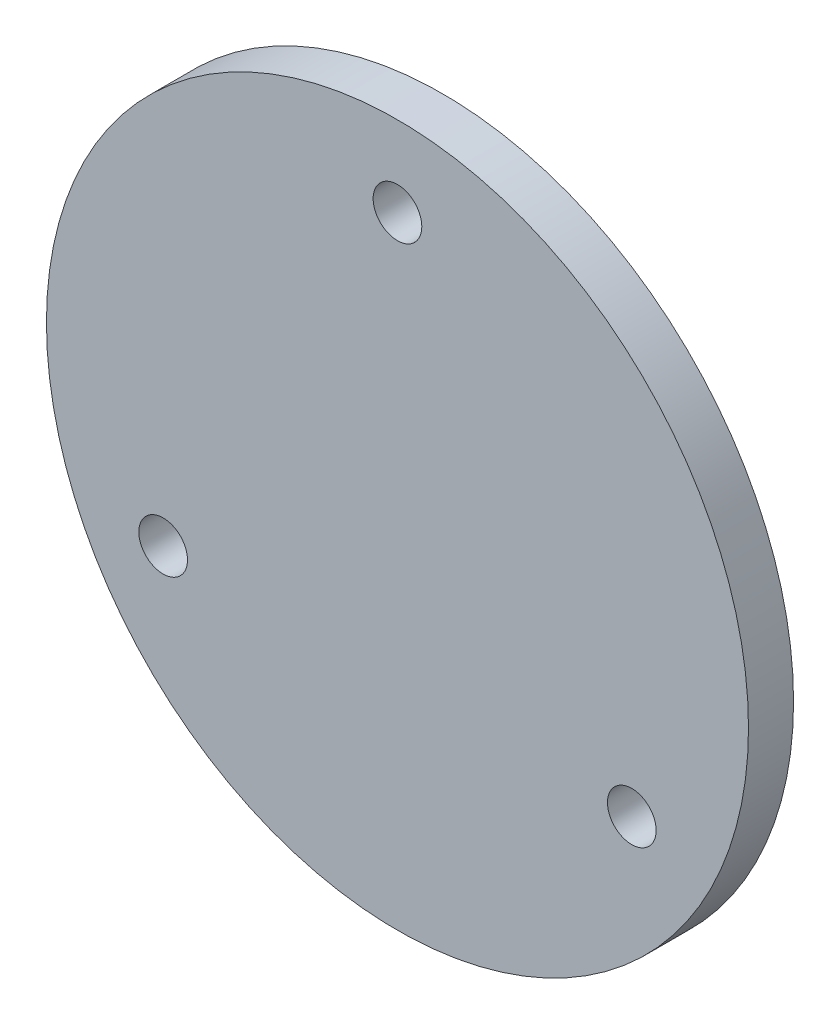
from build123d import *

# Parameters (mm, degrees)
SKETCH1_R           = 49.4665
BOSS_EXTRUDE1_DEPTH = 6.35
SKETCH6_R           = 3.429
CUT_EXTRUDE2_DEPTH  = 7.35


with BuildPart() as part:
    # Sketch1 → Boss-Extrude1 (new body)
    with BuildSketch(Plane.XY):
        Circle(SKETCH1_R)
    extrude(amount=BOSS_EXTRUDE1_DEPTH)

    # Sketch6 → Cut-Extrude2 (cut, through all)
    with BuildSketch(Plane.XY.offset(6.35)):
        with Locations((0, 38.128211777)):
            Circle(SKETCH6_R)
        with Locations((-33.02, -19.064105889)):
            Circle(SKETCH6_R)
        with Locations((33.02, -19.064105889)):
            Circle(SKETCH6_R)
    extrude(amount=-CUT_EXTRUDE2_DEPTH, mode=Mode.SUBTRACT)


solid = part.part
